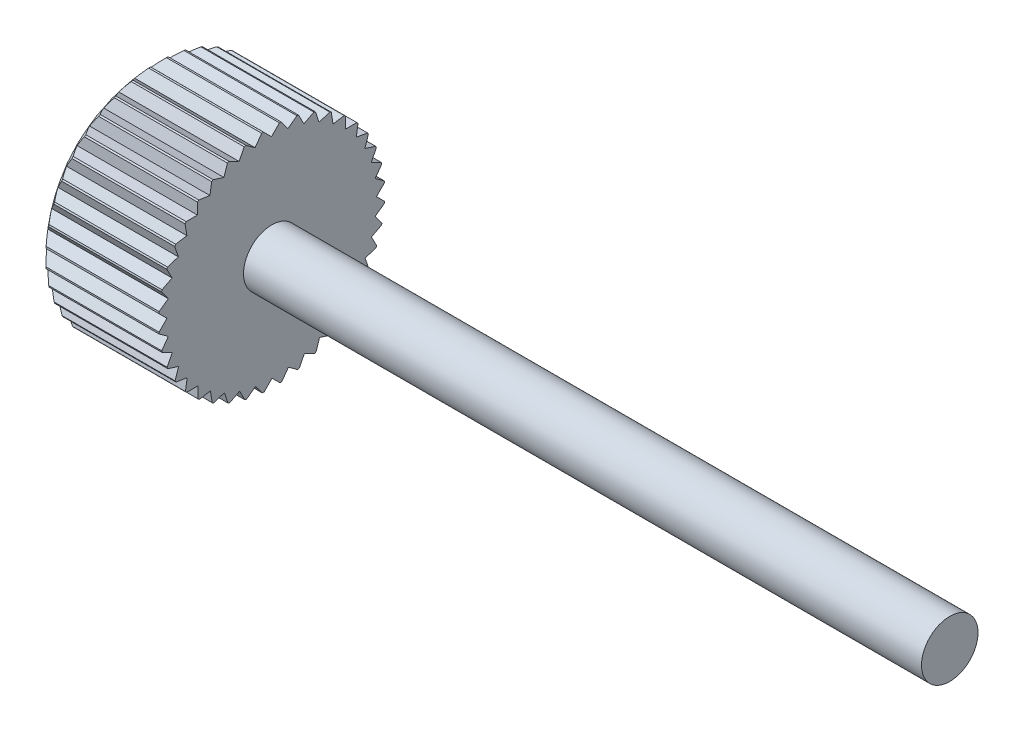
from build123d import *

# Parameters (mm, degrees)
SKETCH1_R           = 2
BOSS_EXTRUDE1_DEPTH = 2
SKETCH2_R           = 0.5
BOSS_EXTRUDE2_DEPTH = 12
DOME1_FACE_RADIUS   = 2
DOME1_HEIGHT        = 0.8
CUT_EXTRUDE1_DEPTH  = 3.8
CIRPATTERN1_COUNT   = 40


with BuildPart() as part:
    # Sketch1 → Boss-Extrude1 (new body)
    with BuildSketch(Plane(origin=(0, 0, 0), x_dir=(0, 0, -1), z_dir=(1, 0, 0))):
        Circle(SKETCH1_R)
    extrude(amount=BOSS_EXTRUDE1_DEPTH)

    # Sketch2 → Boss-Extrude2 (add)
    with BuildSketch(Plane(origin=(2, 0, 0), x_dir=(0, 0, -1), z_dir=(1, 0, 0))):
        Circle(SKETCH2_R)
    extrude(amount=BOSS_EXTRUDE2_DEPTH)

    # Dome1: a dome of height H over a round flat face of radius A is a cap of a sphere of radius (A * A + H * H) / (2 * H)
    dome1_r = (DOME1_FACE_RADIUS * DOME1_FACE_RADIUS + DOME1_HEIGHT * DOME1_HEIGHT) / (2 * DOME1_HEIGHT)
    dome1_base = Plane((0, 0, 0), z_dir=(-1, 0, 0))
    with Locations(dome1_base.offset(DOME1_HEIGHT - dome1_r)):
        dome1_ball = Sphere(dome1_r, mode=Mode.PRIVATE)
    add(split(dome1_ball, bisect_by=dome1_base, keep=Keep.TOP, mode=Mode.PRIVATE))

    # Sketch3 → Cut-Extrude1 (cut, through all)
    with BuildSketch(Plane(origin=(2, 0, 0), x_dir=(0, 0, -1), z_dir=(1, 0, 0))):
        with BuildLine():
            Line((-0.005039775, 1.853565527), (0.135996541, 1.995370878))
            ThreePointArc((0.135996541, 1.995370878), (-0.005437904, 1.999992607), (-0.146845126, 1.994601842))
            Line((-0.146845126, 1.994601842), (-0.005039775, 1.853565527))
        make_face()
    cut_extrude1 = extrude(amount=-CUT_EXTRUDE1_DEPTH, mode=Mode.SUBTRACT)

    # CirPattern1: Cut-Extrude1 ×40 about axis
    cirpattern1_axis = Axis((0, 0, 0), (1, 0, 0))
    for i in range(1, CIRPATTERN1_COUNT):
        add(cut_extrude1.rotate(cirpattern1_axis, i * 360 / CIRPATTERN1_COUNT), mode=Mode.SUBTRACT)


solid = part.part
